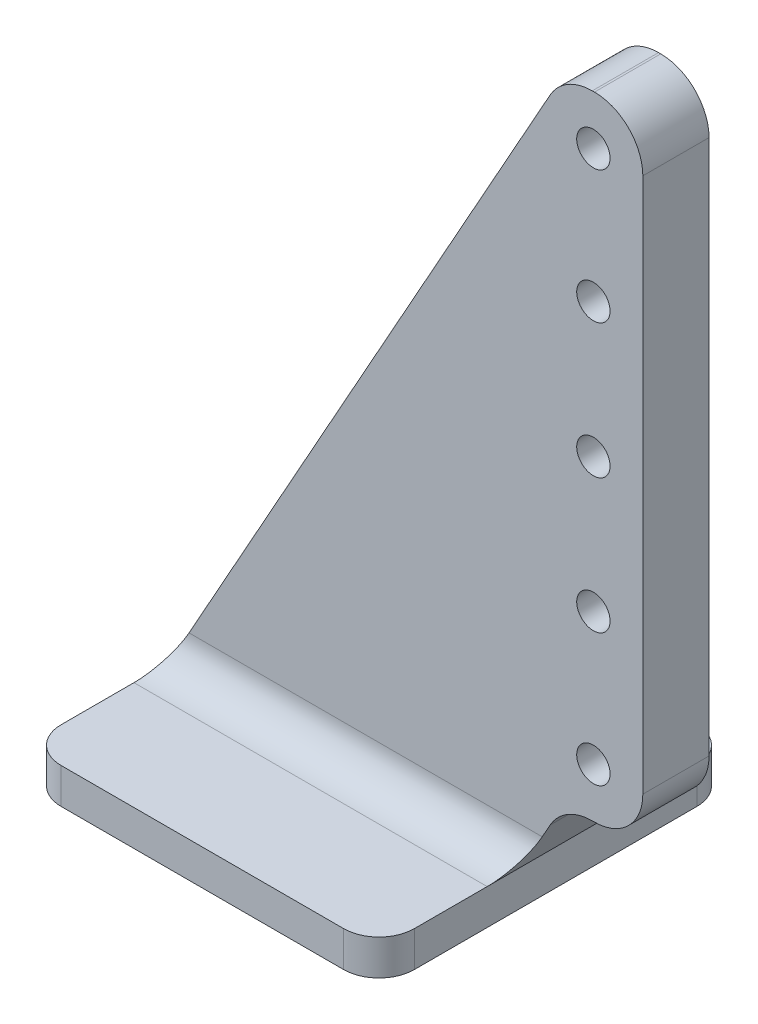
from build123d import *

# Parameters (mm, degrees)
SKETCH1_R           = 0.5999988
BOSS_EXTRUDE1_DEPTH = 2.38125
SKETCH2_W           = 12.7
SKETCH2_H           = 12.7
BOSS_EXTRUDE2_DEPTH = 1.27635
FILLET1_R           = 1.27


with BuildPart() as part:
    # Sketch1 → Boss-Extrude1 (new body)
    with BuildSketch(Plane.XY):
        with BuildLine():
            Line((0, 0), (13.692383752, 24.509366916))
            ThreePointArc((13.692383752, 24.509366916), (14.330250369, 25.160900132), (15.210137069, 25.4))
            Line((15.210137069, 25.4), (15.289057138, 25.4))
            ThreePointArc((15.289057138, 25.4), (16.518390537, 24.890793433), (17.027597104, 23.661460034))
            Line((17.027597104, 23.661460034), (17.027597104, 4.405539966))
            ThreePointArc((17.027597104, 4.405539966), (16.518390537, 3.176206567), (15.289057138, 2.667))
            Line((15.289057138, 2.667), (15.210137069, 2.667))
            ThreePointArc((15.210137069, 2.667), (14.330250369, 2.427900132), (13.692383752, 1.776366916))
            Line((13.692383752, 1.776366916), (12.7, 0))
            Line((12.7, 0), (0, 0))
        make_face()
        with Locations((15.249597104, 4.445)):
            Circle(SKETCH1_R, mode=Mode.SUBTRACT)
        with Locations((15.249597104, 23.622)):
            Circle(SKETCH1_R, mode=Mode.SUBTRACT)
        with Locations((15.249597104, 14.0335)):
            Circle(SKETCH1_R, mode=Mode.SUBTRACT)
        with Locations((15.249597104, 18.8595)):
            Circle(SKETCH1_R, mode=Mode.SUBTRACT)
        with Locations((15.249597104, 9.2075)):
            Circle(SKETCH1_R, mode=Mode.SUBTRACT)
    extrude(amount=BOSS_EXTRUDE1_DEPTH)

    # Sketch2 → Boss-Extrude2 (add)
    with BuildSketch(Plane.XZ):
        with Locations((6.35, 1.190625)):
            Rectangle(SKETCH2_W, SKETCH2_H)
    extrude(amount=BOSS_EXTRUDE2_DEPTH)

    # Fillet1
    fillet1_edges = [part.edges().sort_by_distance(p)[0] for p in [
        (6.35, 0, 0),
        (6.35, 0, 2.38125),
        (12.7, -0.638175, 7.540625),
        (12.7, -0.638175, -5.159375),
        (0, -0.638175, -5.159375),
        (0, -0.638175, 7.540625),
    ]]
    fillet(fillet1_edges, radius=FILLET1_R)


solid = part.part
